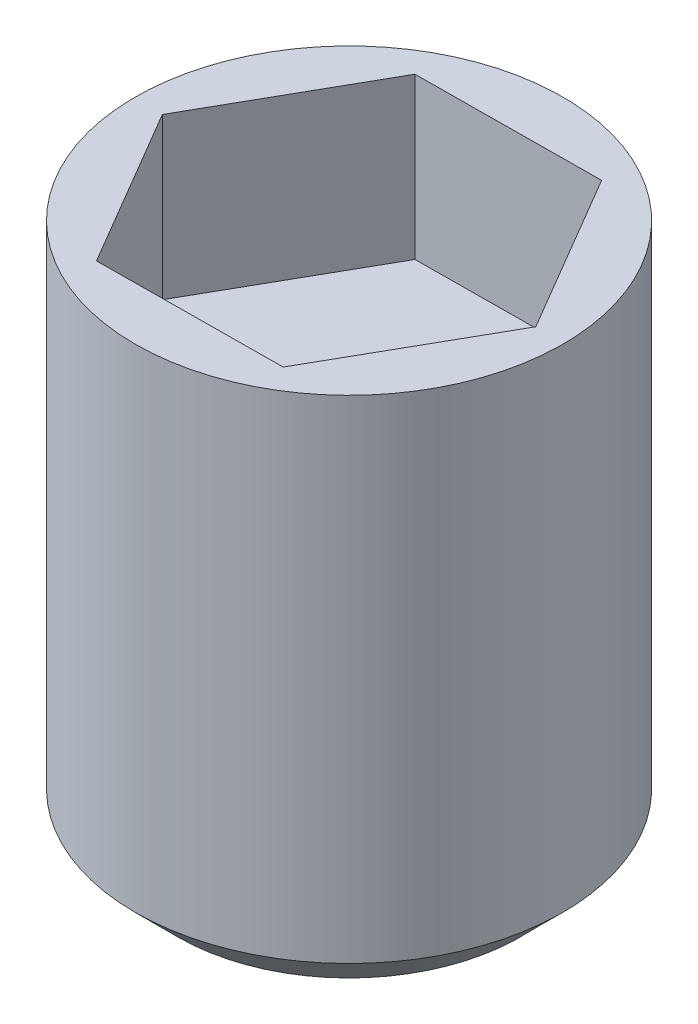
from build123d import *

# Parameters (mm, degrees)
CUT_EXTRUDE_1_DEPTH = 3


with BuildPart() as part:
    # Эскиз1 → Повернуть1 (revolve)
    with BuildSketch(Plane.XY):
        Polygon((0, 0), (3.2, 0), (4, 0.8), (4, 10), (0, 10), align=None)
    revolve(axis=Axis((0, 68.644575989, 0), (0, -1, 0)))

    # Эскиз2 → Вырез-Вытянуть1 (cut)
    with BuildSketch(Plane(origin=(0, 10, 0), x_dir=(1, 0, 0), z_dir=(0, 1, 0))):
        Polygon((1.755265403, -2.986476748), (3.463997433, 0.026866056), (1.708732029, 3.013342804), (-1.755265403, 2.986476748), (-3.463997433, -0.026866056), (-1.708732029, -3.013342804), align=None)
    extrude(amount=-CUT_EXTRUDE_1_DEPTH, mode=Mode.SUBTRACT)


solid = part.part
